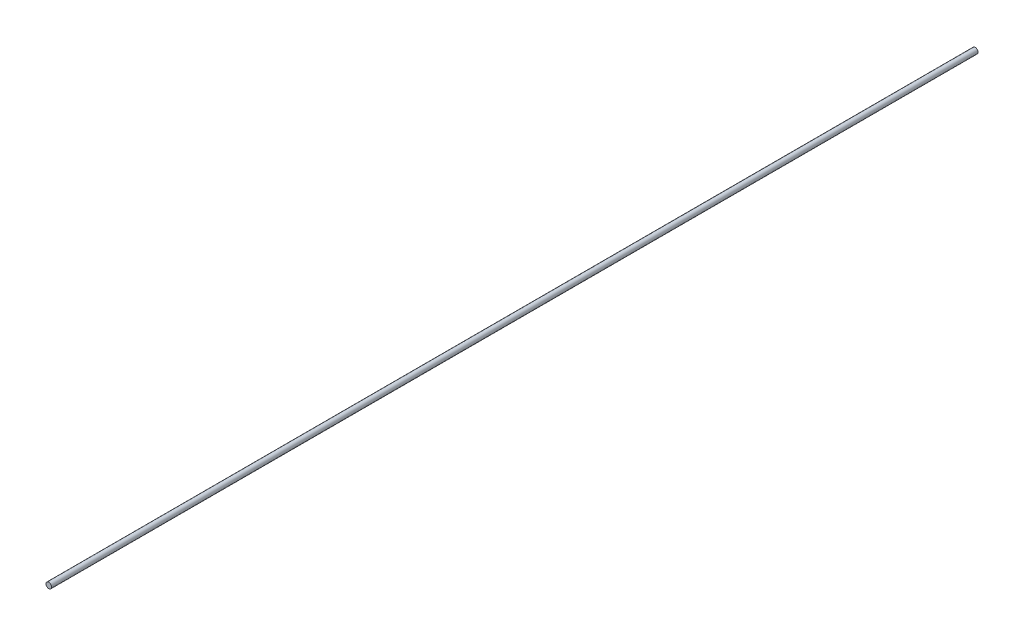
from build123d import *

# Parameters (mm, degrees)
SKETCH1_R           = 0.4826
BOSS_EXTRUDE1_DEPTH = 160


with BuildPart() as part:
    # Sketch1 → Boss-Extrude1 (new body)
    with BuildSketch(Plane.XY):
        Circle(SKETCH1_R)
    extrude(amount=BOSS_EXTRUDE1_DEPTH)


solid = part.part
